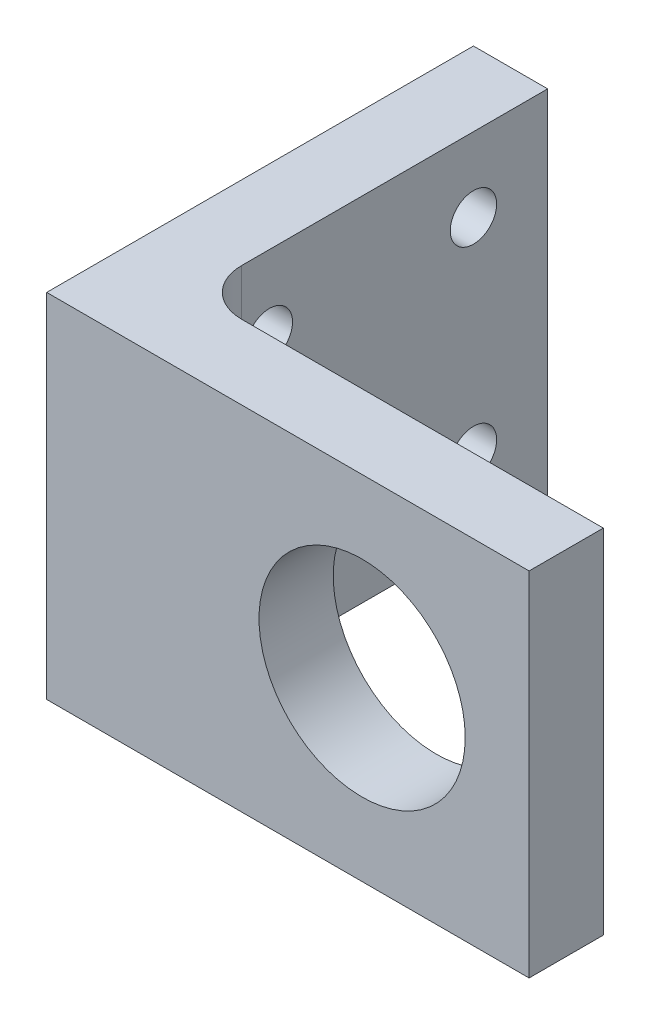
from build123d import *

# Parameters (mm, degrees)
SKETCH1_W        = 52
SKETCH1_H        = 38
SKETCH1_R        = 11.1125
FACEUP_DEPTH     = 8
SKETCH8_W        = 8
SKETCH8_H        = 38
FACEDOWN_DEPTH   = 38
FILLET1_R        = 5
SKETCH9_R        = 2.5
SCREWHOLES_DEPTH = 8


with BuildPart() as part:
    # Sketch1 → FaceUp (new body)
    with BuildSketch(Plane.XY):
        with Locations((26, 19)):
            Rectangle(SKETCH1_W, SKETCH1_H)
        with Locations((34, 19)):
            Circle(SKETCH1_R, mode=Mode.SUBTRACT)
    extrude(amount=FACEUP_DEPTH)

    # Sketch8 → FaceDown (add)
    with BuildSketch(Plane(origin=(0, 0, 0), x_dir=(-1, 0, 0), z_dir=(0, 0, -1))):
        with Locations((-4, 19)):
            Rectangle(SKETCH8_W, SKETCH8_H)
    extrude(amount=FACEDOWN_DEPTH)

    # Fillet1
    fillet1_edges = [part.edges().sort_by_distance(p)[0] for p in [
        (8, 19, 0),
    ]]
    fillet(fillet1_edges, radius=FILLET1_R)

    # Sketch9 → ScrewHoles (cut)
    with BuildSketch(Plane.ZY):
        with Locations((-8, 30)):
            Circle(SKETCH9_R)
        with Locations((-30, 30)):
            Circle(SKETCH9_R)
        with Locations((-8, 8)):
            Circle(SKETCH9_R)
        with Locations((-30, 8)):
            Circle(SKETCH9_R)
    extrude(amount=-SCREWHOLES_DEPTH, mode=Mode.SUBTRACT)


solid = part.part
